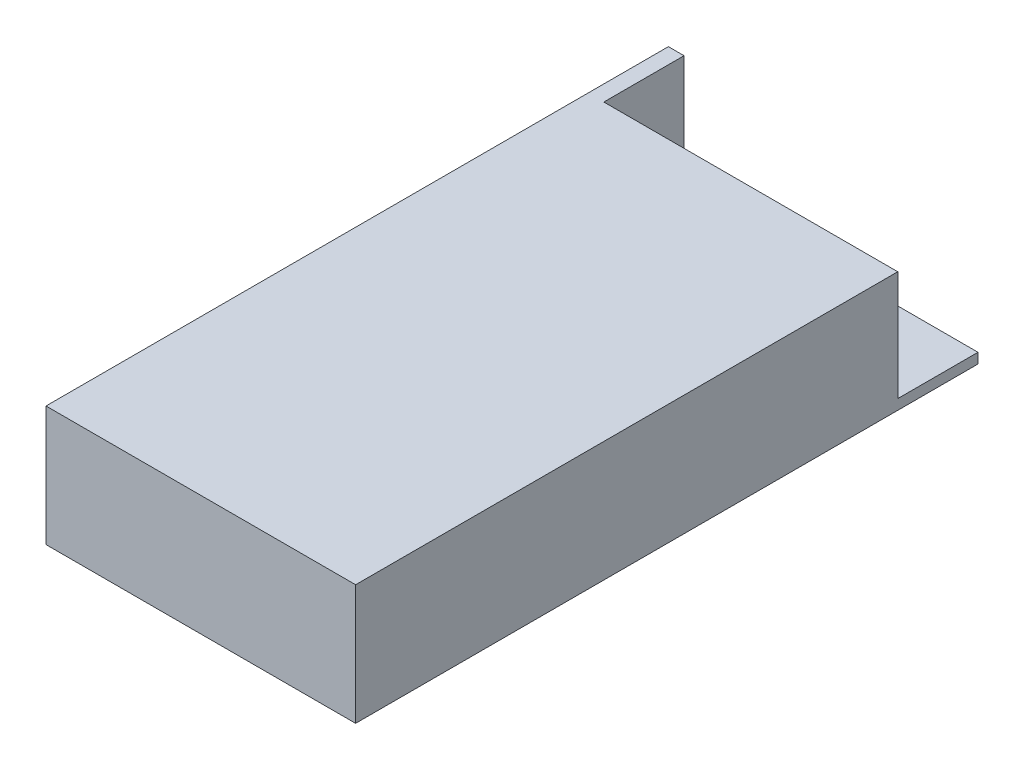
from build123d import *

# Parameters (mm, degrees)
SKETCH1_W                       = 98
SKETCH1_H                       = 197
BOSS_EXTRUDE1_DEPTH             = 19
M3X0_5_TAPPED_HOLE1_D           = 2.5
M3X0_5_TAPPED_HOLE1_DEPTH       = 7.493
M3X0_5_TAPPED_HOLE1_CBORE_D     = 3
M3X0_5_TAPPED_HOLE1_CBORE_DEPTH = 5.9944
M3X0_5_TAPPED_HOLE1_TIP         = 0.751075774
SKETCH6_W                       = 93.03788075
SKETCH6_H                       = 34.777327968
CUT_EXTRUDE2_DEPTH              = 25.4
CUT_EXTRUDE1_DEPTH              = 0.1016


with BuildPart() as part:
    # Sketch1 → Boss-Extrude1 (new body, symmetric)
    with BuildSketch(Plane(origin=(0, 0, 0), x_dir=(1, 0, 0), z_dir=(0, 1, 0))):
        Rectangle(SKETCH1_W, SKETCH1_H)
    extrude(amount=BOSS_EXTRUDE1_DEPTH, both=True)

    # M3x0.5 Tapped Hole1
    with Locations(Plane.XZ.offset(19)):
        with Locations((-40, -36.5), (40, -36.5), (-40, 83.5), (40, 83.5)):
            CounterBoreHole(M3X0_5_TAPPED_HOLE1_D / 2, M3X0_5_TAPPED_HOLE1_CBORE_D / 2, M3X0_5_TAPPED_HOLE1_CBORE_DEPTH, depth=M3X0_5_TAPPED_HOLE1_DEPTH)
            with Locations((0, 0, -(M3X0_5_TAPPED_HOLE1_DEPTH + M3X0_5_TAPPED_HOLE1_TIP / 2))):  # 118° drill point
                Cone(0, M3X0_5_TAPPED_HOLE1_D / 2, M3X0_5_TAPPED_HOLE1_TIP, mode=Mode.SUBTRACT)

    # Sketch6 → Cut-Extrude2 (cut)
    with BuildSketch(Plane(origin=(0, 0, -98.5), x_dir=(-1, 0, 0), z_dir=(0, 0, -1))):
        with Locations((-2.481059625, 1.611336016)):
            Rectangle(SKETCH6_W, SKETCH6_H)
    extrude(amount=-CUT_EXTRUDE2_DEPTH, mode=Mode.SUBTRACT)

    # Sketch3 → Cut-Extrude1 (cut)
    with BuildSketch(Plane(origin=(0, 0, -73.1), x_dir=(-1, 0, 0), z_dir=(0, 0, -1))):
        with BuildLine():
            add(Edge.make_bspline(
                [(3.785576923, 6.512820513), (3.903157344, 6.5098424), (4.134094991, 6.503993141), (4.473502305, 6.459218196), (4.797524835, 6.38175656), (5.108802087, 6.278590864), (5.403610773, 6.140969336), (5.684169907, 5.974626281), (5.949811949, 5.777818991), (6.196956456, 5.552068823), (6.42311978, 5.306444556), (6.622375316, 5.044320348), (6.789366335, 4.767281093), (6.926500549, 4.4761593), (7.034085169, 4.171613358), (7.108324006, 3.852019667), (7.155746078, 3.519448958), (7.161290132, 3.292614503), (7.164102564, 3.177544071)],
                knots=[0, 0, 0, 0, 1.065120563, 2.091984664, 3.0946048, 4.079830382, 5.057816894, 6.036188127, 7.030412546, 8.04752943, 9.064399622, 10.05169764, 11.02544977, 11.989514704, 12.962713494, 13.945757189, 14.957906945, 16, 16, 16, 16], degree=3))
            add(Edge.make_bspline(
                [(7.164102564, 3.177544071), (7.161290544, 3.063321275), (7.155747726, 2.838174912), (7.108270086, 2.507714663), (7.033809986, 2.190050114), (6.927499618, 1.885711573), (6.791019107, 1.594377993), (6.622916154, 1.316815948), (6.424902814, 1.052934444), (6.199556099, 0.805624322), (5.953899922, 0.578843197), (5.690410724, 0.381233237), (5.415014272, 0.211190896), (5.124166659, 0.075511945), (4.821725163, -0.032931396), (4.504982949, -0.106868311), (4.175424201, -0.154560518), (3.950686808, -0.160036968), (3.836458333, -0.162820513)],
                knots=[0, 0, 0, 0, 1.043624062, 2.057103931, 3.04512605, 4.022047818, 4.998200453, 5.980619268, 6.982898556, 8.009068085, 9.034988726, 10.034168286, 11.015286542, 11.987931943, 12.962482838, 13.94673481, 14.956375938, 16, 16, 16, 16], degree=3))
            add(Edge.make_bspline(
                [(3.836458333, -0.162820513), (3.721388497, -0.160009482), (3.49455522, -0.154468193), (3.161566599, -0.106967644), (2.841748406, -0.032688422), (2.536015226, 0.073464412), (2.244196568, 0.210655674), (1.965721704, 0.377940762), (1.701708394, 0.576436575), (1.454345511, 0.801710217), (1.228014823, 1.046950033), (1.030694241, 1.309720753), (0.863371536, 1.584867082), (0.726640918, 1.87315259), (0.618392542, 2.173183636), (0.544542372, 2.486961588), (0.49676143, 2.812697548), (0.491255352, 3.034481092), (0.488461538, 3.147015224)],
                knots=[0, 0, 0, 0, 1.053102029, 2.075944431, 3.073151272, 4.055350789, 5.033113405, 6.020478099, 7.024410459, 8.052272461, 9.079885166, 10.07527673, 11.055994387, 12.023226415, 12.992069828, 13.970394897, 14.97016774, 16, 16, 16, 16], degree=3))
            add(Edge.make_bspline(
                [(0.488461538, 3.147015224), (0.48943152, 3.222548781), (0.491359246, 3.372663005), (0.514567031, 3.595578123), (0.548243261, 3.814908316), (0.596506731, 4.030029893), (0.659628755, 4.240416251), (0.734108862, 4.447518349), (0.825076867, 4.649237391), (0.927911757, 4.846528973), (1.042686751, 5.036317602), (1.169461325, 5.215713417), (1.303782637, 5.386221797), (1.451036222, 5.543424219), (1.606368916, 5.691893852), (1.772300545, 5.829349067), (1.947818617, 5.957029336), (2.133678363, 6.072091954), (2.32530009, 6.176157813), (2.522833673, 6.265460314), (2.72359631, 6.34210674), (2.928528314, 6.40422938), (3.137085486, 6.453273217), (3.349723009, 6.486669416), (3.566271483, 6.509936392), (3.71216059, 6.511855003), (3.785576923, 6.512820513)],
                knots=[0, 0, 0, 0, 1.037015668, 2.060948919, 3.074880161, 4.083647147, 5.086022904, 6.090072063, 7.104153813, 8.122640571, 9.144368836, 10.147691507, 11.138137339, 12.123020368, 13.103399296, 14.087645067, 15.080126199, 16.082011238, 17.087798457, 18.072939717, 19.057185487, 20.037253025, 21.01195951, 21.997135196, 22.992090687, 24, 24, 24, 24], degree=3))
        make_face()
        with BuildLine():
            add(Edge.make_bspline(
                [(3.813561699, 5.861538462), (3.753300864, 5.860803875), (3.633355291, 5.859341724), (3.455039061, 5.840081783), (3.279067981, 5.812631842), (3.10540571, 5.773476797), (2.93477887, 5.720129444), (2.765597016, 5.658732368), (2.599402904, 5.583945532), (2.43674519, 5.49944934), (2.279056411, 5.405924869), (2.130261938, 5.302561806), (1.98997657, 5.191784144), (1.858543786, 5.073333353), (1.736349517, 4.946606218), (1.620988701, 4.813523941), (1.517085317, 4.670282653), (1.421861485, 4.520766629), (1.336648403, 4.365170618), (1.260874117, 4.205132725), (1.198890844, 4.039347493), (1.148340533, 3.869613521), (1.106430876, 3.69619963), (1.079880756, 3.517790305), (1.06040919, 3.33528203), (1.059030613, 3.211943523), (1.058333333, 3.149559295)],
                knots=[0, 0, 0, 0, 1.008559885, 2.007477868, 2.99961109, 3.989939068, 4.984837346, 5.991145699, 7.001802488, 8.033829008, 9.059044045, 10.069351652, 11.065060232, 12.050310815, 13.029377138, 14.011219647, 14.996725999, 15.989392538, 16.977580475, 17.965360261, 18.951710183, 19.937753436, 20.929683414, 21.935841486, 22.955955122, 24, 24, 24, 24], degree=3))
            add(Edge.make_bspline(
                [(1.058333333, 3.149559295), (1.060646297, 3.05782498), (1.065196613, 2.877355204), (1.105033918, 2.612890143), (1.166396643, 2.358729966), (1.256852151, 2.116265359), (1.369973981, 1.88341216), (1.509722767, 1.662236027), (1.675292822, 1.452677184), (1.863368078, 1.256198625), (2.068967846, 1.076864094), (2.287285798, 0.919450481), (2.515983058, 0.786263314), (2.755656011, 0.677759825), (3.005025118, 0.591781301), (3.265697246, 0.532855784), (3.535935937, 0.494074601), (3.720141554, 0.490350315), (3.813561699, 0.488461538)],
                knots=[0, 0, 0, 0, 1.032063989, 2.030389145, 3.003944642, 3.970395727, 4.937377036, 5.913328081, 6.909231446, 7.93887556, 8.970685674, 9.976071282, 10.964166581, 11.944589148, 12.933237628, 13.927779006, 14.949070134, 16, 16, 16, 16], degree=3))
            add(Edge.make_bspline(
                [(3.813561699, 0.488461538), (3.876353223, 0.489324239), (4.000887675, 0.491035234), (4.186118122, 0.508268548), (4.368011535, 0.535903511), (4.546312786, 0.575691986), (4.720819515, 0.62548906), (4.892260086, 0.684648795), (5.058808413, 0.758456122), (5.222565547, 0.840004549), (5.379313015, 0.932968834), (5.528947195, 1.032823763), (5.667696472, 1.143438261), (5.79903093, 1.260129149), (5.92172688, 1.385249273), (6.034954609, 1.518635961), (6.138332849, 1.661131154), (6.233520522, 1.81042039), (6.318435013, 1.966442163), (6.39241995, 2.127060293), (6.455187188, 2.291879277), (6.505857476, 2.461136842), (6.545563956, 2.634511525), (6.57292324, 2.812235467), (6.592061121, 2.993953131), (6.593503618, 3.116859841), (6.594230769, 3.178816106)],
                knots=[0, 0, 0, 0, 1.047197238, 2.076906641, 3.100256066, 4.114471768, 5.12198147, 6.126382909, 7.136867548, 8.15857795, 9.17633901, 10.174870724, 11.156907918, 12.133735059, 13.104061851, 14.077631395, 15.04955518, 16.038496417, 17.029181396, 18.010275684, 18.986308667, 19.968651475, 20.955262928, 21.950658345, 22.966943676, 24, 24, 24, 24], degree=3))
            add(Edge.make_bspline(
                [(6.594230769, 3.178816106), (6.593503036, 3.240348521), (6.592059442, 3.3624094), (6.572932381, 3.542859742), (6.545535051, 3.719304854), (6.506051281, 3.89105204), (6.455160288, 4.058145078), (6.392408988, 4.220427035), (6.318412802, 4.378502474), (6.233489309, 4.531980699), (6.138029173, 4.679254866), (6.033718188, 4.820047815), (5.918755342, 4.951715503), (5.796425269, 5.077508448), (5.663672377, 5.194743762), (5.521098015, 5.303460335), (5.370433056, 5.406281847), (5.210907929, 5.499038223), (5.04627247, 5.584698331), (4.877337147, 5.658088008), (4.70601578, 5.720448853), (4.532744033, 5.773638204), (4.356063487, 5.812478488), (4.177167969, 5.840106521), (3.996304986, 5.859335021), (3.87466943, 5.860801651), (3.813561699, 5.861538462)],
                knots=[0, 0, 0, 0, 1.02996197, 2.043119294, 3.035359645, 4.018872909, 4.991431989, 5.957985074, 6.929999688, 7.912076566, 8.892894881, 9.867085534, 10.843653904, 11.817741046, 12.803660682, 13.806313499, 14.818574707, 15.856120519, 16.894564902, 17.924820532, 18.937903209, 19.946497019, 20.957711757, 21.963978472, 22.977135795, 24, 24, 24, 24], degree=3))
        make_face(mode=Mode.SUBTRACT)
        with BuildLine():
            Line((8.466666667, 6.35), (9.036538462, 6.35))
            Line((9.036538462, 6.35), (9.036538462, 2.545342548))
            add(Edge.make_bspline(
                [(9.036538462, 2.545342548), (9.036453655, 2.491493213), (9.036292719, 2.389304821), (9.037367708, 2.243856618), (9.040378277, 2.114548014), (9.042276309, 2.000880569), (9.046498757, 1.90337587), (9.049942356, 1.821505663), (9.054370224, 1.75565761), (9.059691737, 1.717229359), (9.061979167, 1.700711138)],
                knots=[0, 0, 0, 0, 1.528628734, 2.90083645, 4.128790002, 5.200304208, 6.127813768, 6.898992206, 7.526736466, 8, 8, 8, 8], degree=3))
            add(Edge.make_bspline(
                [(9.061979167, 1.700711138), (9.071372556, 1.641117724), (9.089630051, 1.525288773), (9.136159908, 1.360355176), (9.201143089, 1.211708102), (9.278146895, 1.074709045), (9.379624632, 0.953171206), (9.501188189, 0.841208636), (9.648467855, 0.743288362), (9.812226383, 0.653751889), (9.988729599, 0.581788096), (10.16909004, 0.527371564), (10.350596587, 0.494208417), (10.472110487, 0.490368411), (10.532451923, 0.488461538)],
                knots=[0, 0, 0, 0, 1.035780045, 2.013197591, 2.933192213, 3.817615948, 4.702609284, 5.640816605, 6.646850145, 7.73207398, 8.84249596, 9.914020372, 10.964143139, 12, 12, 12, 12], degree=3))
            add(Edge.make_bspline(
                [(10.532451923, 0.488461538), (10.584256566, 0.49040981), (10.687566643, 0.494295099), (10.841066881, 0.518355124), (10.990564221, 0.561717579), (11.136796884, 0.617669712), (11.273867955, 0.691597485), (11.401853914, 0.776997436), (11.516088481, 0.87716574), (11.620333705, 0.988019222), (11.711111375, 1.113095716), (11.789799017, 1.249671767), (11.854253204, 1.399802725), (11.886082171, 1.505311462), (11.902433894, 1.559515224)],
                knots=[0, 0, 0, 0, 0.994687771, 1.983630487, 2.973142513, 3.978332533, 4.983357753, 5.956394766, 6.925816176, 7.893390482, 8.871859704, 9.88551698, 10.913711441, 12, 12, 12, 12], degree=3))
            add(Edge.make_bspline(
                [(11.902433894, 1.559515224), (11.907876979, 1.581919066), (11.920006364, 1.631843855), (11.931340289, 1.716246768), (11.943144985, 1.815831757), (11.951335705, 1.931314332), (11.959320776, 2.062307525), (11.964097923, 2.209493735), (11.966305968, 2.372338506), (11.966963974, 2.485980214), (11.967307692, 2.545342548)],
                knots=[0, 0, 0, 0, 0.558680831, 1.244966039, 2.062412453, 2.990489873, 4.051219941, 5.244515665, 6.560634259, 8, 8, 8, 8], degree=3))
            Line((11.967307692, 2.545342548), (11.967307692, 6.35))
            Line((11.967307692, 6.35), (12.537179487, 6.35))
            Line((12.537179487, 6.35), (12.537179487, 2.514813702))
            add(Edge.make_bspline(
                [(12.537179487, 2.514813702), (12.53671844, 2.445692357), (12.535818679, 2.310797851), (12.528016204, 2.113128956), (12.515575648, 1.925617119), (12.497998688, 1.748237132), (12.474708697, 1.581623729), (12.448809368, 1.424316507), (12.415826501, 1.277444649), (12.377303044, 1.139862977), (12.333263893, 1.008897831), (12.276220667, 0.88460363), (12.211950502, 0.763201791), (12.135723918, 0.646528507), (12.050068981, 0.53406719), (11.95309236, 0.426499868), (11.848001382, 0.322107598), (11.733049039, 0.223568178), (11.610130228, 0.133201007), (11.479610591, 0.053739337), (11.342492737, -0.013432083), (11.199133094, -0.068724118), (11.049470483, -0.110297748), (10.893501131, -0.141276959), (10.730870023, -0.158879699), (10.620262718, -0.161495772), (10.564252804, -0.162820513)],
                knots=[0, 0, 0, 0, 1.316592851, 2.569410997, 3.76748051, 4.895814652, 5.963796859, 6.97159953, 7.931736103, 8.829262218, 9.692595152, 10.560224239, 11.431080259, 12.30701507, 13.211635791, 14.121146779, 15.063487852, 16.031507147, 17.00238618, 17.966455255, 18.938106653, 19.907068911, 20.888905087, 21.893141452, 22.933117798, 24, 24, 24, 24], degree=3))
            add(Edge.make_bspline(
                [(10.564252804, -0.162820513), (10.503167433, -0.161396724), (10.383318152, -0.158603257), (10.206719087, -0.142596267), (10.037420473, -0.112445752), (9.873634239, -0.074055568), (9.717590252, -0.02110793), (9.56719786, 0.04075581), (9.425032824, 0.116733125), (9.288788805, 0.201266853), (9.162106747, 0.296380125), (9.045815744, 0.400048726), (8.939723808, 0.510611982), (8.845619173, 0.629266932), (8.761942711, 0.755090743), (8.689860752, 0.888439364), (8.627969581, 1.029261166), (8.596026238, 1.127147687), (8.579877804, 1.176632612)],
                knots=[0, 0, 0, 0, 1.13879206, 2.234305948, 3.301075583, 4.341971843, 5.366689343, 6.369221514, 7.369726634, 8.367512178, 9.355451585, 10.318319045, 11.268648973, 12.207971039, 13.137398894, 14.081662264, 15.030215811, 16, 16, 16, 16], degree=3))
            add(Edge.make_bspline(
                [(8.579877804, 1.176632612), (8.57048496, 1.210437426), (8.550111672, 1.283760819), (8.528294347, 1.40511202), (8.509953584, 1.544839085), (8.492707786, 1.702951578), (8.482531533, 1.879572051), (8.473609895, 2.074623941), (8.466603815, 2.2883431), (8.46664513, 2.437213435), (8.466666667, 2.514813702)],
                knots=[0, 0, 0, 0, 0.625038921, 1.35572334, 2.194682327, 3.136881307, 4.189498639, 5.346923369, 6.617055217, 8, 8, 8, 8], degree=3))
            Line((8.466666667, 2.514813702), (8.466666667, 6.35))
        make_face()
        Polygon((13.432692308, 5.698717949), (13.432692308, 6.35), (16.770512821, 6.35), (16.770512821, 5.698717949), (15.386538462, 5.698717949), (15.386538462, 0), (14.816666667, 0), (14.816666667, 5.698717949), align=None)
        with BuildLine():
            Line((17.747435897, 6.35), (18.992758413, 6.35))
            add(Edge.make_bspline(
                [(18.992758413, 6.35), (19.078412486, 6.349905845), (19.242529493, 6.349725441), (19.477869666, 6.344255831), (19.691610179, 6.336950261), (19.883290155, 6.326823112), (20.053499362, 6.314855012), (20.201467605, 6.298069169), (20.328357943, 6.280542633), (20.404388216, 6.262723796), (20.4390625, 6.254597356)],
                knots=[0, 0, 0, 0, 1.415646017, 2.712440637, 3.8905458, 4.950247383, 5.884950622, 6.709939814, 7.411656543, 8, 8, 8, 8], degree=3))
            add(Edge.make_bspline(
                [(20.4390625, 6.254597356), (20.482956483, 6.242583247), (20.569710141, 6.218838126), (20.69471632, 6.171278942), (20.813649725, 6.114887014), (20.92691841, 6.050617866), (21.033130475, 5.975714057), (21.133870577, 5.893211922), (21.228249685, 5.801206647), (21.315737067, 5.700730162), (21.396082343, 5.59346921), (21.465260481, 5.477822593), (21.523185593, 5.355736942), (21.572866671, 5.227297177), (21.608623439, 5.091424733), (21.635559957, 4.949063698), (21.65265711, 4.800229332), (21.654294615, 4.698520715), (21.655128205, 4.646744792)],
                knots=[0, 0, 0, 0, 0.999701418, 1.975846123, 2.934577507, 3.890451536, 4.834027766, 5.787354733, 6.749476667, 7.726910423, 8.712836071, 9.690891519, 10.682875813, 11.679750201, 12.712814741, 13.765529915, 14.8625177, 16, 16, 16, 16], degree=3))
            add(Edge.make_bspline(
                [(21.655128205, 4.646744792), (21.65436362, 4.594533682), (21.652867658, 4.492379121), (21.634912969, 4.342931348), (21.610728193, 4.200113697), (21.573540684, 4.064242837), (21.524834963, 3.936125653), (21.467699381, 3.813804275), (21.398786404, 3.699359728), (21.319602213, 3.592376529), (21.231515749, 3.492754259), (21.134899704, 3.401214846), (21.030144131, 3.318294118), (20.917581948, 3.24380618), (20.796115794, 3.179478359), (20.667587886, 3.121861534), (20.530881065, 3.07347261), (20.436279647, 3.04801807), (20.38818109, 3.035076122)],
                knots=[0, 0, 0, 0, 1.121902311, 2.195077645, 3.232258892, 4.234102512, 5.217864754, 6.176164875, 7.132989551, 8.084763148, 9.034132444, 9.988522005, 10.94243251, 11.903244335, 12.886203696, 13.894208494, 14.929344452, 16, 16, 16, 16], degree=3))
            add(Edge.make_bspline(
                [(20.38818109, 3.035076122), (20.348398641, 3.026616142), (20.261213091, 3.008075604), (20.117625581, 2.987377404), (19.950447524, 2.969710614), (19.759907102, 2.956464264), (19.546175346, 2.94512431), (19.309136636, 2.936110768), (19.048325667, 2.931158033), (18.866404982, 2.930902595), (18.771424279, 2.930769231)],
                knots=[0, 0, 0, 0, 0.601384939, 1.31797006, 2.144135048, 3.087295005, 4.142315834, 5.309527816, 6.595305764, 8, 8, 8, 8], degree=3))
            Line((18.771424279, 2.930769231), (18.317307692, 2.930769231))
            Line((18.317307692, 2.930769231), (18.317307692, 0))
            Line((18.317307692, 0), (17.747435897, 0))
            Line((17.747435897, 0), (17.747435897, 6.35))
        make_face()
        with BuildLine():
            Line((18.317307692, 5.698717949), (18.317307692, 3.582051282))
            Line((18.317307692, 3.582051282), (19.429066506, 3.568058894))
            add(Edge.make_bspline(
                [(19.429066506, 3.568058894), (19.4833498, 3.568030839), (19.58814258, 3.567976679), (19.739519728, 3.575207013), (19.879962292, 3.583553693), (20.009038879, 3.595774583), (20.126807674, 3.613048864), (20.233465048, 3.630487303), (20.328183976, 3.655715604), (20.439035385, 3.689684601), (20.562558029, 3.747619489), (20.696937725, 3.831711433), (20.810821503, 3.938900717), (20.909370412, 4.059419783), (20.987576791, 4.193493918), (21.044828377, 4.33694756), (21.078467334, 4.488309516), (21.082978, 4.59188371), (21.08525641, 4.644200721)],
                knots=[0, 0, 0, 0, 1.160613943, 2.240541288, 3.23993089, 4.169200891, 5.011653406, 5.7853311, 6.478053781, 7.106038997, 8.262395093, 9.384106736, 10.481365981, 11.59014053, 12.70357646, 13.786202915, 14.881775077, 16, 16, 16, 16], degree=3))
            add(Edge.make_bspline(
                [(21.08525641, 4.644200721), (21.082965609, 4.695252024), (21.078411779, 4.796735696), (21.044564713, 4.94546859), (20.987688101, 5.087410511), (20.908845422, 5.219804537), (20.813157943, 5.339889939), (20.701943421, 5.444206155), (20.575463647, 5.52806553), (20.457810428, 5.582191627), (20.353305419, 5.615239341), (20.262533149, 5.638362123), (20.160042925, 5.65682358), (20.045801382, 5.671772392), (19.920693983, 5.684569386), (19.783645898, 5.693252516), (19.635176288, 5.698335158), (19.532105681, 5.698587263), (19.478675881, 5.698717949)],
                knots=[0, 0, 0, 0, 1.120700087, 2.227813068, 3.331159281, 4.466773991, 5.599788987, 6.693661531, 7.80175334, 8.91857717, 9.525282508, 10.207424825, 10.974604443, 11.810962634, 12.737642355, 13.736264703, 14.826523623, 16, 16, 16, 16], degree=3))
            Line((19.478675881, 5.698717949), (18.317307692, 5.698717949))
        make_face(mode=Mode.SUBTRACT)
        with BuildLine():
            Line((22.957692308, 6.35), (23.527564103, 6.35))
            Line((23.527564103, 6.35), (23.527564103, 2.545342548))
            add(Edge.make_bspline(
                [(23.527564103, 2.545342548), (23.527479296, 2.491493213), (23.52731836, 2.389304821), (23.528393349, 2.243856618), (23.531403918, 2.114548014), (23.53330195, 2.000880569), (23.537524398, 1.90337587), (23.540967997, 1.821505663), (23.545395865, 1.75565761), (23.550717378, 1.717229359), (23.553004808, 1.700711138)],
                knots=[0, 0, 0, 0, 1.528628734, 2.90083645, 4.128790002, 5.200304208, 6.127813768, 6.898992206, 7.526736466, 8, 8, 8, 8], degree=3))
            add(Edge.make_bspline(
                [(23.553004808, 1.700711138), (23.562398197, 1.641117724), (23.580655692, 1.525288773), (23.627185549, 1.360355176), (23.69216873, 1.211708102), (23.769172536, 1.074709045), (23.870650273, 0.953171206), (23.99221383, 0.841208636), (24.139493496, 0.743288362), (24.303252024, 0.653751889), (24.47975524, 0.581788096), (24.660115681, 0.527371564), (24.841622228, 0.494208417), (24.963136128, 0.490368411), (25.023477564, 0.488461538)],
                knots=[0, 0, 0, 0, 1.035780045, 2.013197591, 2.933192213, 3.817615948, 4.702609284, 5.640816605, 6.646850145, 7.73207398, 8.84249596, 9.914020372, 10.964143139, 12, 12, 12, 12], degree=3))
            add(Edge.make_bspline(
                [(25.023477564, 0.488461538), (25.075282207, 0.49040981), (25.178592284, 0.494295099), (25.332092523, 0.518355124), (25.481589862, 0.561717579), (25.627822525, 0.617669712), (25.764893596, 0.691597485), (25.892879555, 0.776997436), (26.007114122, 0.87716574), (26.111359346, 0.988019222), (26.202137016, 1.113095716), (26.280824658, 1.249671767), (26.345278845, 1.399802725), (26.377107812, 1.505311462), (26.393459535, 1.559515224)],
                knots=[0, 0, 0, 0, 0.994687771, 1.983630487, 2.973142513, 3.978332533, 4.983357753, 5.956394766, 6.925816176, 7.893390482, 8.871859704, 9.88551698, 10.913711441, 12, 12, 12, 12], degree=3))
            add(Edge.make_bspline(
                [(26.393459535, 1.559515224), (26.39890262, 1.581919066), (26.411032005, 1.631843855), (26.42236593, 1.716246768), (26.434170626, 1.815831757), (26.442361346, 1.931314332), (26.450346417, 2.062307525), (26.455123564, 2.209493735), (26.457331609, 2.372338506), (26.457989615, 2.485980214), (26.458333333, 2.545342548)],
                knots=[0, 0, 0, 0, 0.558680831, 1.244966039, 2.062412453, 2.990489873, 4.051219941, 5.244515665, 6.560634259, 8, 8, 8, 8], degree=3))
            Line((26.458333333, 2.545342548), (26.458333333, 6.35))
            Line((26.458333333, 6.35), (27.028205128, 6.35))
            Line((27.028205128, 6.35), (27.028205128, 2.514813702))
            add(Edge.make_bspline(
                [(27.028205128, 2.514813702), (27.027744081, 2.445692357), (27.02684432, 2.310797851), (27.019041846, 2.113128956), (27.006601289, 1.925617119), (26.989024329, 1.748237132), (26.965734338, 1.581623729), (26.939835009, 1.424316507), (26.906852142, 1.277444649), (26.868328685, 1.139862977), (26.824289534, 1.008897831), (26.767246308, 0.88460363), (26.702976143, 0.763201791), (26.626749559, 0.646528507), (26.541094622, 0.53406719), (26.444118001, 0.426499868), (26.339027023, 0.322107598), (26.22407468, 0.223568178), (26.101155869, 0.133201007), (25.970636232, 0.053739337), (25.833518378, -0.013432083), (25.690158735, -0.068724118), (25.540496124, -0.110297748), (25.384526772, -0.141276959), (25.221895664, -0.158879699), (25.111288359, -0.161495772), (25.055278446, -0.162820513)],
                knots=[0, 0, 0, 0, 1.316592851, 2.569410997, 3.76748051, 4.895814652, 5.963796859, 6.97159953, 7.931736103, 8.829262218, 9.692595152, 10.560224239, 11.431080259, 12.30701507, 13.211635791, 14.121146779, 15.063487852, 16.031507147, 17.00238618, 17.966455255, 18.938106653, 19.907068911, 20.888905087, 21.893141452, 22.933117798, 24, 24, 24, 24], degree=3))
            add(Edge.make_bspline(
                [(25.055278446, -0.162820513), (24.994193074, -0.161396724), (24.874343793, -0.158603257), (24.697744728, -0.142596267), (24.528446114, -0.112445752), (24.36465988, -0.074055568), (24.208615893, -0.02110793), (24.058223501, 0.04075581), (23.916058465, 0.116733125), (23.779814446, 0.201266853), (23.653132388, 0.296380125), (23.536841385, 0.400048726), (23.430749449, 0.510611982), (23.336644814, 0.629266932), (23.252968352, 0.755090743), (23.180886393, 0.888439364), (23.118995222, 1.029261166), (23.087051879, 1.127147687), (23.070903446, 1.176632612)],
                knots=[0, 0, 0, 0, 1.13879206, 2.234305948, 3.301075583, 4.341971843, 5.366689343, 6.369221514, 7.369726634, 8.367512178, 9.355451585, 10.318319045, 11.268648973, 12.207971039, 13.137398894, 14.081662264, 15.030215811, 16, 16, 16, 16], degree=3))
            add(Edge.make_bspline(
                [(23.070903446, 1.176632612), (23.061510601, 1.210437426), (23.041137313, 1.283760819), (23.019319988, 1.40511202), (23.000979225, 1.544839085), (22.983733427, 1.702951578), (22.973557174, 1.879572051), (22.964635536, 2.074623941), (22.957629456, 2.2883431), (22.957670771, 2.437213435), (22.957692308, 2.514813702)],
                knots=[0, 0, 0, 0, 0.625038921, 1.35572334, 2.194682327, 3.136881307, 4.189498639, 5.346923369, 6.617055217, 8, 8, 8, 8], degree=3))
            Line((22.957692308, 2.514813702), (22.957692308, 6.35))
        make_face()
        Polygon((27.923717949, 5.698717949), (27.923717949, 6.35), (31.261538462, 6.35), (31.261538462, 5.698717949), (29.877564103, 5.698717949), (29.877564103, 0), (29.307692308, 0), (29.307692308, 5.698717949), align=None)
        with BuildLine():
            Line((31.587179487, 1.224969952), (32.123978365, 1.546794872))
            add(Edge.make_bspline(
                [(32.123978365, 1.546794872), (32.17390431, 1.463220916), (32.269560494, 1.303096443), (32.429129388, 1.086728284), (32.594470527, 0.902828371), (32.766808318, 0.752466525), (32.945090824, 0.634086402), (33.130481892, 0.550262353), (33.322356778, 0.497981941), (33.452937854, 0.491631784), (33.518129006, 0.488461538)],
                knots=[0, 0, 0, 0, 1.272034388, 2.437168799, 3.508375237, 4.49857839, 5.41946034, 6.295179144, 7.148887113, 8, 8, 8, 8], degree=3))
            add(Edge.make_bspline(
                [(33.518129006, 0.488461538), (33.573803739, 0.490012159), (33.684179027, 0.493086267), (33.846670525, 0.522624293), (34.004480366, 0.568003441), (34.154356038, 0.632992846), (34.29422951, 0.711621241), (34.416887371, 0.806592163), (34.52292532, 0.912920565), (34.609664713, 1.031543381), (34.676212777, 1.15911878), (34.727361244, 1.290066577), (34.755745878, 1.426443837), (34.760021702, 1.518265676), (34.762179487, 1.564603365)],
                knots=[0, 0, 0, 0, 1.095163259, 2.171163733, 3.241058638, 4.321873601, 5.38011039, 6.391990106, 7.366004449, 8.327778327, 9.272591725, 10.192022065, 11.087607919, 12, 12, 12, 12], degree=3))
            add(Edge.make_bspline(
                [(34.762179487, 1.564603365), (34.759504666, 1.617473193), (34.754067146, 1.724949826), (34.708108604, 1.883517768), (34.635810685, 2.040440002), (34.569112745, 2.137506584), (34.534485176, 2.187900641)],
                knots=[0, 0, 0, 0, 0.938893495, 1.908633276, 2.914225137, 4, 4, 4, 4], degree=3))
            add(Edge.make_bspline(
                [(34.534485176, 2.187900641), (34.506054205, 2.224271307), (34.446366937, 2.30062697), (34.343755449, 2.414283326), (34.223348356, 2.5315196), (34.089266192, 2.65681246), (33.936624731, 2.784334606), (33.770204812, 2.920167053), (33.585757525, 3.0591442), (33.456399867, 3.152348712), (33.389653446, 3.200440705)],
                knots=[0, 0, 0, 0, 0.722233717, 1.516239348, 2.393582979, 3.351407094, 4.387010283, 5.505090956, 6.712668013, 8, 8, 8, 8], degree=3))
            add(Edge.make_bspline(
                [(33.389653446, 3.200440705), (33.322844195, 3.248026857), (33.195109996, 3.339007956), (33.016477997, 3.474034871), (32.856740186, 3.597485891), (32.716606541, 3.71052317), (32.596138701, 3.813162039), (32.49438737, 3.904416871), (32.413944559, 3.986755618), (32.369212291, 4.040170623), (32.349128606, 4.064152644)],
                knots=[0, 0, 0, 0, 1.452282411, 2.77665338, 3.964542531, 5.026858415, 5.96415736, 6.766646006, 7.446254459, 8, 8, 8, 8], degree=3))
            add(Edge.make_bspline(
                [(32.349128606, 4.064152644), (32.321056988, 4.101528811), (32.265850384, 4.175034059), (32.192977774, 4.289923444), (32.131039579, 4.407531369), (32.082485062, 4.528173866), (32.041597922, 4.650157237), (32.014097105, 4.775073068), (31.996876999, 4.902360847), (31.995113538, 4.988019627), (31.994230769, 5.030899439)],
                knots=[0, 0, 0, 0, 1.068054152, 2.10047183, 3.106115577, 4.101338837, 5.06977816, 6.043150881, 7.020423561, 8, 8, 8, 8], degree=3))
            add(Edge.make_bspline(
                [(31.994230769, 5.030899439), (31.996598791, 5.09808203), (32.001284221, 5.231011231), (32.040909159, 5.425195738), (32.103452837, 5.610591095), (32.191073563, 5.785361843), (32.304026189, 5.944957266), (32.434738171, 6.091213164), (32.590424724, 6.214164734), (32.761244484, 6.321592326), (32.948218187, 6.405677076), (33.144144541, 6.469106283), (33.349334943, 6.505045936), (33.488314915, 6.510203524), (33.558834135, 6.512820513)],
                knots=[0, 0, 0, 0, 1.005424448, 1.989358655, 2.955360095, 3.929531133, 4.905563448, 5.876582895, 6.856512386, 7.866279853, 8.892233794, 9.918561126, 10.94386622, 12, 12, 12, 12], degree=3))
            add(Edge.make_bspline(
                [(33.558834135, 6.512820513), (33.633662717, 6.510239598), (33.782472883, 6.505106981), (34.001365032, 6.460480032), (34.21211376, 6.386637384), (34.38164654, 6.302837962), (34.514330265, 6.219142394), (34.615517937, 6.142906427), (34.71805674, 6.055140158), (34.822773783, 5.955609812), (34.927894693, 5.843402135), (35.0349801, 5.719285599), (35.144280416, 5.584018705), (35.214594619, 5.487454254), (35.250641026, 5.437950721)],
                knots=[0, 0, 0, 0, 1.286793592, 2.559021753, 3.825965368, 5.121522368, 5.803751409, 6.523245864, 7.299691795, 8.125521123, 9.008227632, 9.944561021, 10.946284179, 12, 12, 12, 12], degree=3))
            Line((35.250641026, 5.437950721), (34.735466747, 5.047435897))
            add(Edge.make_bspline(
                [(34.735466747, 5.047435897), (34.704359126, 5.087511093), (34.644453123, 5.164686549), (34.553503911, 5.272765936), (34.467781364, 5.371492978), (34.383325639, 5.457245424), (34.304597193, 5.534719295), (34.228184845, 5.601049139), (34.155188236, 5.656884863), (34.06317327, 5.716472464), (33.947571124, 5.775539263), (33.802456322, 5.825521162), (33.650806938, 5.855556775), (33.54752032, 5.859528042), (33.495232372, 5.861538462)],
                knots=[0, 0, 0, 0, 1.181633172, 2.275549214, 3.290209073, 4.226197932, 5.078386478, 5.862611352, 6.581680152, 7.217281963, 8.414376989, 9.595101626, 10.782541182, 12, 12, 12, 12], degree=3))
            add(Edge.make_bspline(
                [(33.495232372, 5.861538462), (33.42963411, 5.859340092), (33.303134041, 5.855100742), (33.12353747, 5.808800198), (32.961895634, 5.735898822), (32.823007409, 5.633727362), (32.707370322, 5.512676418), (32.623721847, 5.373377638), (32.57337512, 5.219558137), (32.567231441, 5.112258274), (32.564102564, 5.057612179)],
                knots=[0, 0, 0, 0, 1.14458467, 2.207223713, 3.21896685, 4.227309161, 5.202851033, 6.127160689, 7.046193047, 8, 8, 8, 8], degree=3))
            add(Edge.make_bspline(
                [(32.564102564, 5.057612179), (32.564815808, 5.02359164), (32.566243463, 4.95549493), (32.586154881, 4.854890208), (32.611735092, 4.754539635), (32.65227101, 4.654894377), (32.708233204, 4.554211754), (32.781721166, 4.450758031), (32.874273889, 4.343621359), (32.945170754, 4.27393941), (32.982602163, 4.237149439)],
                knots=[0, 0, 0, 0, 0.858281714, 1.717966888, 2.583508476, 3.4729293, 4.427298488, 5.488583878, 6.674047936, 8, 8, 8, 8], degree=3))
            add(Edge.make_bspline(
                [(32.982602163, 4.237149439), (32.996502082, 4.224745121), (33.029525107, 4.1952753), (33.089897143, 4.147029305), (33.169621934, 4.087515704), (33.266617642, 4.013878716), (33.382672713, 3.928459491), (33.517799908, 3.832350224), (33.670492974, 3.722430891), (33.778845593, 3.64558221), (33.836137821, 3.604947917)],
                knots=[0, 0, 0, 0, 0.420754252, 0.999615792, 1.744751191, 2.668019286, 3.750313428, 4.999500688, 6.413464383, 8, 8, 8, 8], degree=3))
            add(Edge.make_bspline(
                [(33.836137821, 3.604947917), (33.90505512, 3.554798593), (34.03850392, 3.457691378), (34.228382672, 3.311794359), (34.400547152, 3.169104836), (34.555601822, 3.030534034), (34.695078498, 2.897133065), (34.817429792, 2.76729701), (34.923902383, 2.641956042), (35.038527537, 2.481260083), (35.155653866, 2.283900116), (35.256240601, 2.042095312), (35.319665032, 1.799350559), (35.327959067, 1.636197584), (35.332051282, 1.555699119)],
                knots=[0, 0, 0, 0, 1.163667725, 2.253281268, 3.268753668, 4.215851969, 5.092017293, 5.902905408, 6.650798638, 7.335211899, 8.59617414, 9.77448103, 10.901945474, 12, 12, 12, 12], degree=3))
            add(Edge.make_bspline(
                [(35.332051282, 1.555699119), (35.330859046, 1.498769799), (35.328497726, 1.386016689), (35.301354353, 1.220453907), (35.261585818, 1.059652186), (35.201646836, 0.905599168), (35.128489106, 0.755476527), (35.035658914, 0.613222193), (34.928057829, 0.475687727), (34.804625141, 0.346540536), (34.669559004, 0.227983866), (34.526804301, 0.12252114), (34.376127377, 0.034585753), (34.218345631, -0.037170774), (34.05342282, -0.093293013), (33.881414412, -0.133956362), (33.702036871, -0.158913152), (33.580115997, -0.161503519), (33.518129006, -0.162820513)],
                knots=[0, 0, 0, 0, 0.983748083, 1.948392443, 2.894712957, 3.844097841, 4.80183111, 5.778335162, 6.776009319, 7.81870978, 8.863265674, 9.881300176, 10.883814829, 11.87499822, 12.874611388, 13.892143829, 14.928324115, 16, 16, 16, 16], degree=3))
            add(Edge.make_bspline(
                [(33.518129006, -0.162820513), (33.470167741, -0.161893083), (33.374849234, -0.160049904), (33.233862031, -0.143755296), (33.095723062, -0.120700979), (32.962165722, -0.084099452), (32.831469275, -0.039691222), (32.704202149, 0.014988324), (32.580302666, 0.080515246), (32.45907648, 0.15543622), (32.340831906, 0.242626699), (32.226678014, 0.344178614), (32.112869349, 0.457291173), (32.002765073, 0.585036052), (31.894138082, 0.725349431), (31.789130111, 0.879544093), (31.685567566, 1.046780149), (31.620588074, 1.164463947), (31.587179487, 1.224969952)],
                knots=[0, 0, 0, 0, 0.915332311, 1.819136955, 2.706846663, 3.586547465, 4.459518054, 5.340707479, 6.227863349, 7.133153174, 8.059268498, 9.028702269, 10.047606654, 11.120612155, 12.245963614, 13.433783089, 14.680604001, 16, 16, 16, 16], degree=3))
        make_face()
    extrude(amount=-CUT_EXTRUDE1_DEPTH, mode=Mode.SUBTRACT)


solid = part.part
